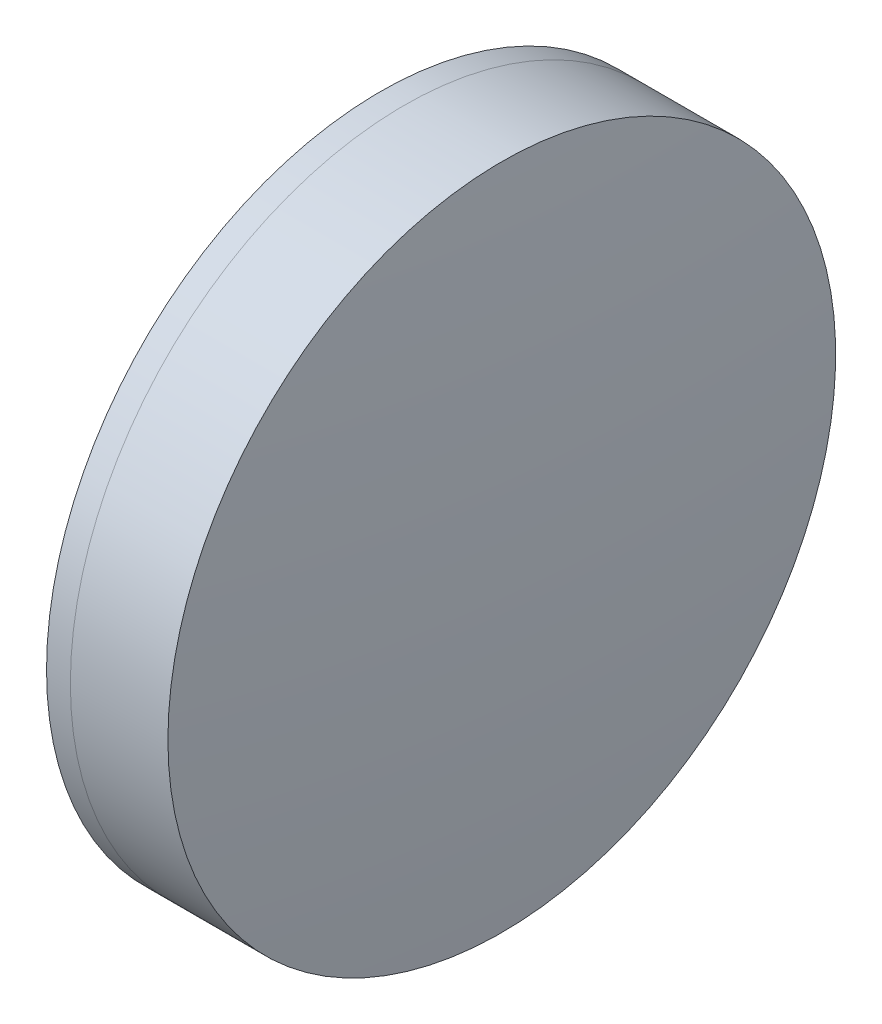
from build123d import *


with BuildPart() as part:
    # 草图1 one side → 旋转1 (revolve)
    with BuildSketch(Plane(origin=(0, 0, 0), x_dir=(1, 0, 0), z_dir=(0, 1, 0)), mode=Mode.PRIVATE) as revolve_1_sk:
        with BuildLine():
            ThreePointArc((534.641653818, 25.4), (529.678090551, 13.128668078), (527.98675322, 0))
            Line((527.98675322, 0), (539.98675322, 0))
            ThreePointArc((539.98675322, 0), (539.099558591, 12.822188797), (536.454883713, 25.4))
            Line((536.454883713, 25.4), (534.641653818, 25.4))
        make_face()
    revolve(revolve_1_sk.sketch.rotate(Axis((124.523309526, 0, 0), (1, 0, 0)), 180), axis=Axis((124.523309526, 0, 0), (1, 0, 0)))  # turned: the seam where the file's is


with BuildPart() as body_2:
    # 草图2 one side → 旋转3 (revolve)
    with BuildSketch(Plane(origin=(0, 0, 0), x_dir=(1, 0, 0), z_dir=(0, 1, 0)), mode=Mode.PRIVATE) as revolve_3_sk:
        with BuildLine():
            Line((543.876494418, 25.4), (536.454883713, 25.4))
            ThreePointArc((536.454883713, 25.4), (539.099558591, 12.822188797), (539.98675322, 0))
            Line((539.98675322, 0), (544.98675322, 0))
            ThreePointArc((544.98675322, 0), (544.709056064, 12.712126834), (543.876494418, 25.4))
        make_face()
    revolve(revolve_3_sk.sketch.rotate(Axis((-0.551919993, 0, 0), (1, 0, 0)), 180), axis=Axis((-0.551919993, 0, 0), (1, 0, 0)))  # turned: the seam where the file's is


solid = Compound([part.part, body_2.part])
